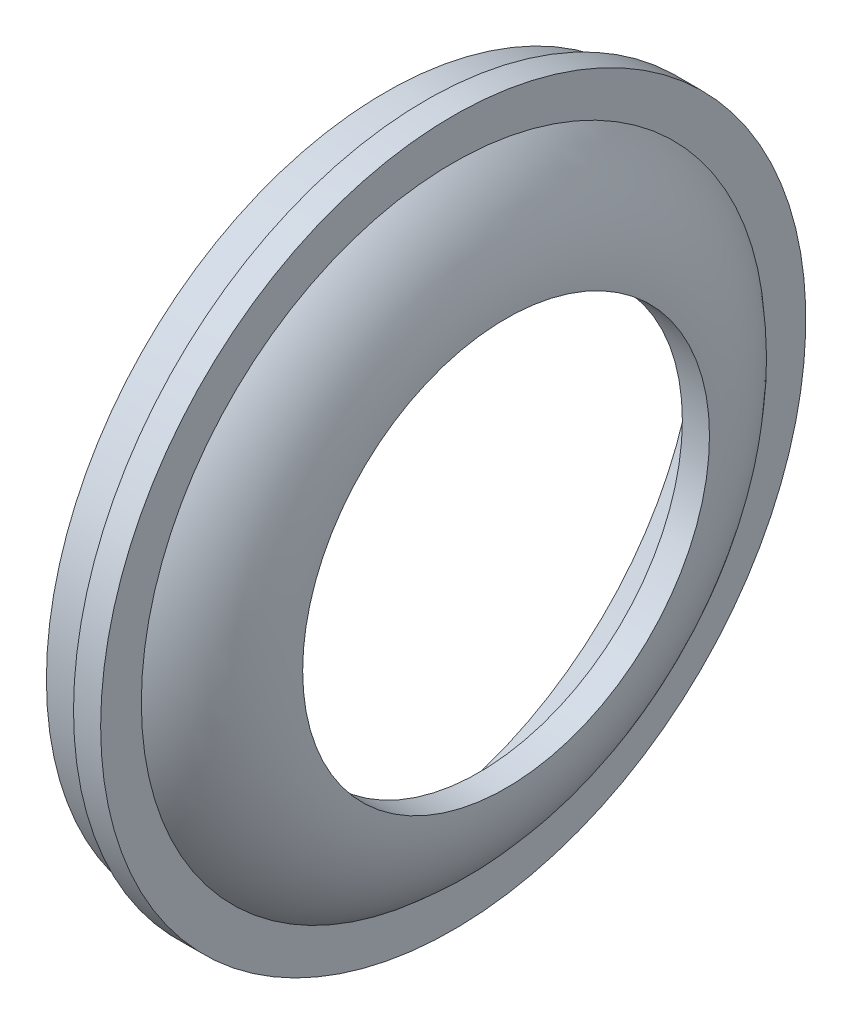
from build123d import *


with BuildPart() as part:
    # Sketch1 → Revolve1 (revolve)
    with BuildSketch(Plane(origin=(0, 0, 0), x_dir=(1, 0, 0), z_dir=(0, 1, 0))):
        with BuildLine():
            Line((1.571907147, 25), (1.571907147, 26))
            Line((1.571907147, 26), (-0.428092853, 26))
            Line((-0.428092853, 26), (-0.428092853, 25))
            Line((-0.428092853, 25), (-3.428092853, 25))
            Line((-3.428092853, 25), (-3.428092853, 23))
            Line((-3.428092853, 23), (0.338990058, 21.425225269))
            ThreePointArc((0.338990058, 21.425225269), (2.644708452, 18.573477692), (3.468758659, 15))
            Line((3.468758659, 15), (5.468758659, 15))
            ThreePointArc((5.468758659, 15), (4.4427399, 19.449310388), (1.571907147, 23))
            Line((1.571907147, 23), (1.571907147, 25))
        make_face()
    revolve(axis=Axis((-17.365592853, 0, 0), (1, 0, 0)))


solid = part.part
